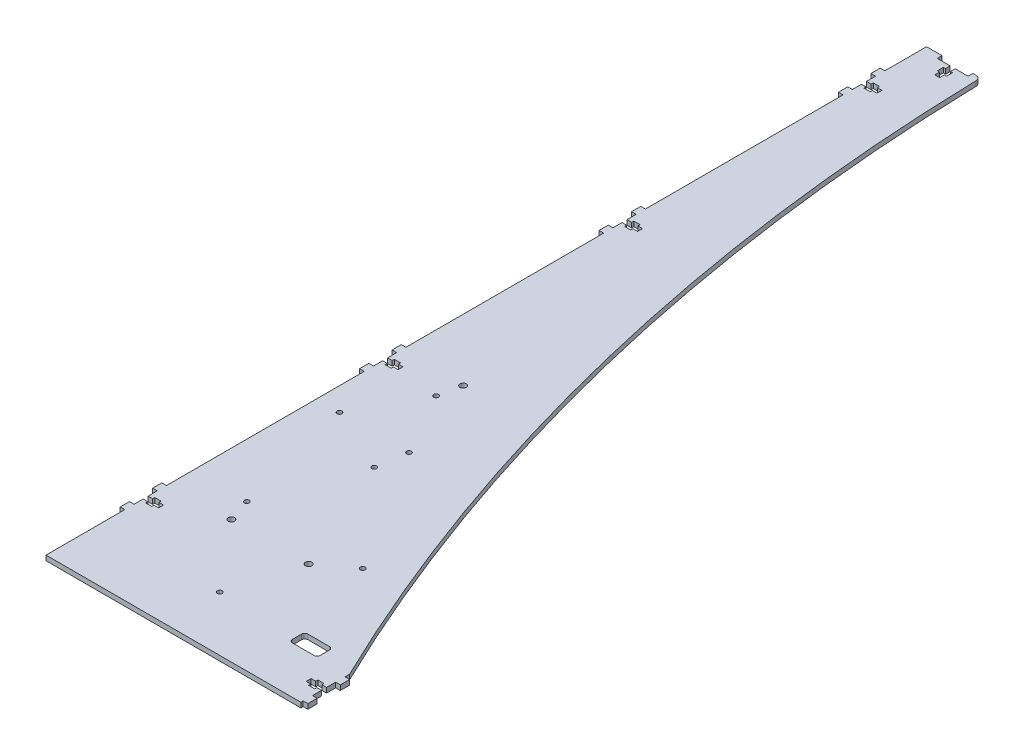
from build123d import *

# Parameters (mm, degrees)
SALIENTE_EXTRUIR1_DEPTH = 3.2
CROQUIS3_R              = 2.05
CORTAR_EXTRUIR2_DEPTH   = 3.2
CORTAR_EXTRUIR3_DEPTH   = 3.2
CORTAR_EXTRUIR4_DEPTH   = 3.2
REDONDEO1_R             = 3
CROQUIS6_R              = 1.55
CORTAR_EXTRUIR5_DEPTH   = 3.2


with BuildPart() as part:
    # Croquis1 → Saliente-Extruir1 (new body)
    with BuildSketch(Plane(origin=(0, 0, 0), x_dir=(1, 0, 0), z_dir=(0, 1, 0))):
        Polygon((7, 66.1), (10, 66.1), (10, 62.9), (7, 62.9), (7, 61.5), (3, 61.5), (3, 62.9), (0, 62.9), (0, 57), (-3, 57), (-3, 51), (0, 51), (0, 0), (165, 0), (165, 1.5), (168, 1.5), (168, 7.5), (165, 7.5), (165, 13.4), (162, 13.4), (162, 12), (158, 12), (158, 13.4), (155, 13.4), (155, 16.6), (158, 16.6), (158, 18), (162, 18), (162, 16.6), (165, 16.6), (165, 22.5), (168, 22.5), (168, 28.5), (165, 28.5), (165, 570), (30, 570), (30, 566.9), (21.6, 566.9), (21.6, 563.9), (23, 563.9), (23, 559.9), (21.6, 559.9), (21.6, 556.9), (18.4, 556.9), (18.4, 559.9), (17, 559.9), (17, 563.9), (18.4, 563.9), (18.4, 566.9), (10, 566.9), (10, 570), (0, 570), (0, 543), (-3, 543), (-3, 537), (0, 537), (0, 531.1), (3, 531.1), (3, 532.5), (7, 532.5), (7, 531.1), (10, 531.1), (10, 527.9), (7, 527.9), (7, 526.5), (3, 526.5), (3, 527.9), (0, 527.9), (0, 522), (-3, 522), (-3, 516), (0, 516), (0, 388), (-3, 388), (-3, 382), (0, 382), (0, 376.1), (3, 376.1), (3, 377.5), (7, 377.5), (7, 376.1), (10, 376.1), (10, 372.9), (7, 372.9), (7, 371.5), (3, 371.5), (3, 372.9), (0, 372.9), (0, 367), (-3, 367), (-3, 361), (0, 361), (0, 233), (-3, 233), (-3, 227), (0, 227), (0, 221.1), (3, 221.1), (3, 222.5), (7, 222.5), (7, 221.1), (10, 221.1), (10, 217.9), (7, 217.9), (7, 216.5), (3, 216.5), (3, 217.9), (0, 217.9), (0, 212), (-3, 212), (-3, 206), (0, 206), (0, 78), (-3, 78), (-3, 72), (0, 72), (0, 66.1), (3, 66.1), (3, 67.5), (7, 67.5), align=None)
    extrude(amount=SALIENTE_EXTRUIR1_DEPTH)

    # Croquis3 → Cortar-Extruir2 (cut)
    with BuildSketch(Plane(origin=(0, 3.2, 0), x_dir=(1, 0, 0), z_dir=(0, 1, 0))):
        with Locations((40, 80)):
            Circle(CROQUIS3_R)
        with Locations((90, 80)):
            Circle(CROQUIS3_R)
        with Locations((40, 230)):
            Circle(CROQUIS3_R)
    extrude(amount=-CORTAR_EXTRUIR2_DEPTH, mode=Mode.SUBTRACT)

    # Croquis4 → Cortar-Extruir3 (cut)
    with BuildSketch(Plane.XZ):
        with BuildLine():
            Line((143, -30.5), (129, -30.5))
            ThreePointArc((129, -30.5), (127.585786438, -31.085786438), (127, -32.5))
            Line((127, -32.5), (127, -38.5))
            ThreePointArc((127, -38.5), (127.585786438, -39.914213562), (129, -40.5))
            Line((129, -40.5), (143, -40.5))
            ThreePointArc((143, -40.5), (144.414213562, -39.914213562), (145, -38.5))
            Line((145, -38.5), (145, -32.5))
            ThreePointArc((145, -32.5), (144.414213562, -31.085786438), (143, -30.5))
        make_face()
    extrude(amount=-CORTAR_EXTRUIR3_DEPTH, mode=Mode.SUBTRACT)

    # Croquis5 → Cortar-Extruir4 (cut)
    with BuildSketch(Plane.XZ):
        with BuildLine():
            Line((35, -570), (165, -570))
            Line((165, -570), (165, -31.5))
            ThreePointArc((165, -31.5), (70.982951471, -293.744955787), (35, -570))
        make_face()
    extrude(amount=-CORTAR_EXTRUIR4_DEPTH, mode=Mode.SUBTRACT)

    # Redondeo1
    redondeo1_edges = [part.edges().sort_by_distance(p)[0] for p in [
        (35, 1.6, -570),
    ]]
    fillet(redondeo1_edges, radius=REDONDEO1_R)

    # Croquis6 → Cortar-Extruir5 (cut)
    with BuildSketch(Plane.XZ):
        with Locations((110, -95)):
            Circle(CROQUIS6_R)
        with Locations((35, -95)):
            Circle(CROQUIS6_R)
        with Locations((60, -175)):
            Circle(CROQUIS6_R)
        with Locations((15, -175)):
            Circle(CROQUIS6_R)
        with Locations((77, -35.5)):
            Circle(CROQUIS6_R)
        with Locations((37, -215.5)):
            Circle(CROQUIS6_R)
        with Locations((57, -155.5)):
            Circle(CROQUIS6_R)
    extrude(amount=-CORTAR_EXTRUIR5_DEPTH, mode=Mode.SUBTRACT)


solid = part.part
